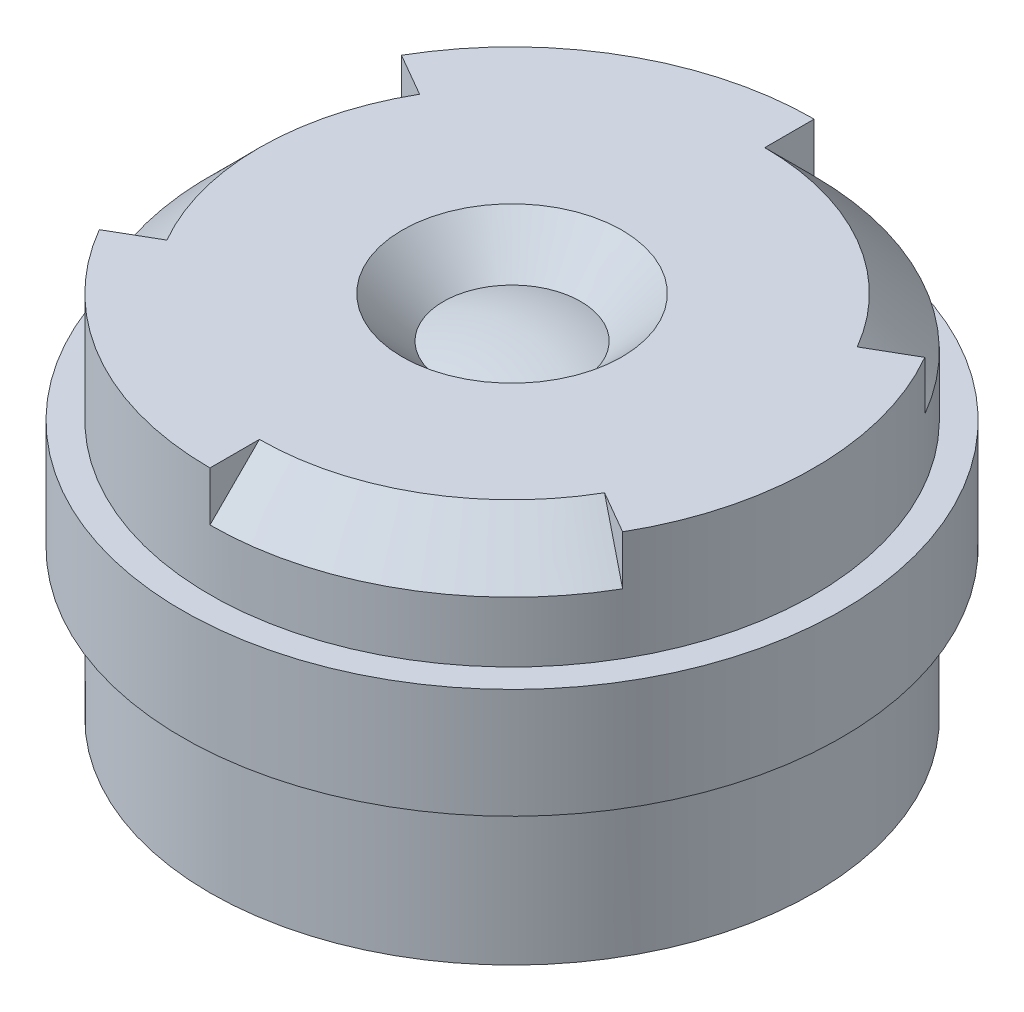
from build123d import *

# Parameters (mm, degrees)
SKIZZE4_W          = 0.25
SKIZZE4_H          = 1
TOOLFACE_ANGLE     = 60
KREISMUSTER1_COUNT = 3


with BuildPart() as part:
    # Skizze3 → Body (revolve)
    with BuildSketch(Plane.XY):
        with BuildLine():
            Line((1, 0.8), (2.75, 0.8))
            Line((2.75, 0.8), (2.75, -2.55))
            Line((2.75, -2.55), (2.1, -2.55))
            Line((2.1, -2.55), (1.8, -2.25))
            ThreePointArc((1.8, -2.25), (0.91241438, -2.474486277), (0, -2.55))
            Line((0, -2.55), (0, 0.525))
            ThreePointArc((0, 0.525), (0.316474723, 0.499842016), (0.625, 0.425))
            Line((0.625, 0.425), (1, 0.8))
        make_face()
    revolve(axis=Axis((0, 0, 0), (0, -1, 0)))

    # Skizze4 → Thread (revolve)
    with BuildSketch(Plane.XY):
        with Locations((2.875, -0.7)):
            Rectangle(SKIZZE4_W, SKIZZE4_H)
    revolve(axis=Axis((0, 0, 0), (0, 1, 0)))

    # Skizze5 → Toolface (revolve, cut)
    with BuildSketch(Plane(origin=(0, 0, 0), x_dir=(0, 0, -1), z_dir=(1, 0, 0))):
        Polygon((2.75, 0.8), (2.75, 0.35), (2.3, 0.8), align=None)
    toolface = revolve(axis=Axis((0, 0, 0), (0, -1, 0)), revolution_arc=TOOLFACE_ANGLE, mode=Mode.SUBTRACT)

    # Kreismuster1: Toolface ×3 about axis
    kreismuster1_axis = Axis((0, 0, 0), (0, 1, 0))
    for i in range(1, KREISMUSTER1_COUNT):
        add(toolface.rotate(kreismuster1_axis, i * 360 / KREISMUSTER1_COUNT), mode=Mode.SUBTRACT)


solid = part.part
